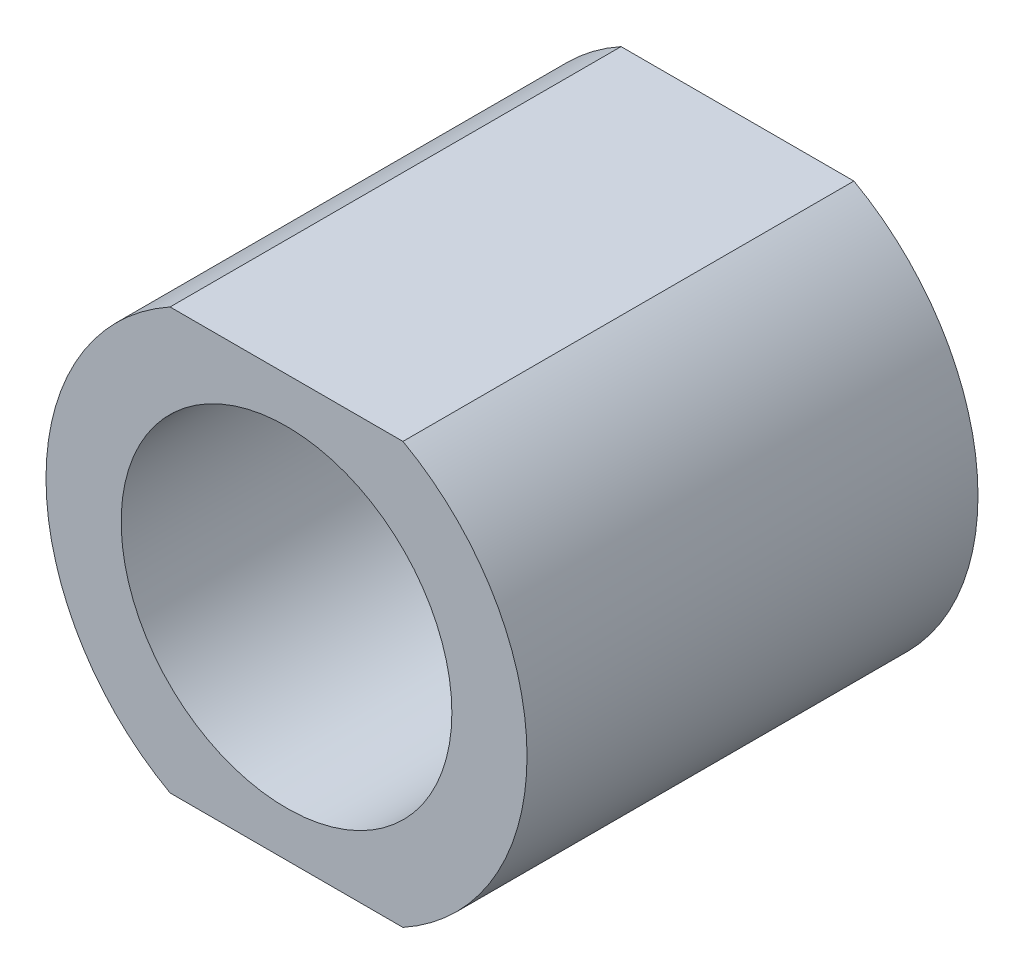
from build123d import *

# Parameters (mm, degrees)
SCHIZZO2_R                   = 16
SCHIZZO2_R_2                 = 11
ESTRUSIONE_ESTRUSIONE1_DEPTH = 30
SCHIZZO3_W                   = 40.226432455
SCHIZZO3_H                   = 6.242620643
SCHIZZO3_W_2                 = 42.895225343
SCHIZZO3_H_2                 = 8.147240474
TAGLIO_ESTRUSIONE1_DEPTH     = 31


with BuildPart() as part:
    # Schizzo2 → Estrusione-Estrusione1 (new body)
    with BuildSketch(Plane.XY):
        Circle(SCHIZZO2_R)
        Circle(SCHIZZO2_R_2, mode=Mode.SUBTRACT)
    extrude(amount=ESTRUSIONE_ESTRUSIONE1_DEPTH)

    # Schizzo3 → Taglio-Estrusione1 (cut, through all)
    with BuildSketch(Plane.XY.offset(30)):
        with Locations((2.318761875, 17.121310322)):
            Rectangle(SCHIZZO3_W, SCHIZZO3_H)
        with Locations((2.584078566, -18.073620237)):
            Rectangle(SCHIZZO3_W_2, SCHIZZO3_H_2)
    extrude(amount=-TAGLIO_ESTRUSIONE1_DEPTH, mode=Mode.SUBTRACT)


solid = part.part
